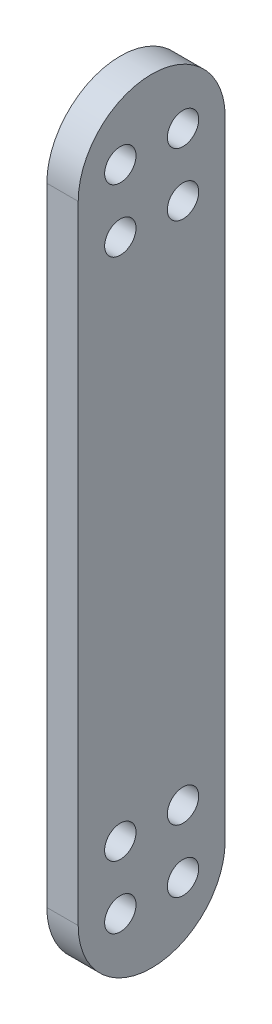
from build123d import *

# Parameters (mm, degrees)
RESSALTO_EXTRUS_O1_DEPTH = 40
ESBO_O2_R                = 5
CORTE_EXTRUS_O1_DEPTH    = 51
ESBO_O3_R                = 2.5
RESSALTO_EXTRUS_O2_DEPTH = 5
ESBO_O4_W                = 80.158201918
ESBO_O4_H                = 76.08775654
CORTE_EXTRUS_O2_DEPTH    = 50


with BuildPart() as part:
    # Esboço1 → Ressalto-extrusão1 (new body)
    with BuildSketch(Plane.XY):
        Polygon((0, 0), (0, 50), (10, 50), (10, 10), (40, 10), (40, 50), (50, 50), (50, 0), align=None)
    extrude(amount=RESSALTO_EXTRUS_O1_DEPTH)

    # Esboço2 → Corte-extrusão1 (cut, through all)
    with BuildSketch(Plane.ZY):
        with Locations((20, 33.697961809)):
            Circle(ESBO_O2_R)
    extrude(amount=-CORTE_EXTRUS_O1_DEPTH, mode=Mode.SUBTRACT)

    # Esboço3 → Ressalto-extrusão2 (add)
    with BuildSketch(Plane.ZY):
        with BuildLine():
            Line((8.284737573, 33.697961809), (8.284737573, 133.697961809))
            ThreePointArc((8.284737573, 133.697961809), (20, 145.413224236), (31.715262427, 133.697961809))
            Line((31.715262427, 133.697961809), (31.715262427, 33.697961809))
            ThreePointArc((31.715262427, 33.697961809), (20, 21.982699383), (8.284737573, 33.697961809))
        make_face()
        with Locations((15, 135.413224236)):
            Circle(ESBO_O3_R, mode=Mode.SUBTRACT)
        with Locations((25, 135.413224236)):
            Circle(ESBO_O3_R, mode=Mode.SUBTRACT)
        with Locations((25, 125.413224236)):
            Circle(ESBO_O3_R, mode=Mode.SUBTRACT)
        with Locations((15, 125.413224236)):
            Circle(ESBO_O3_R, mode=Mode.SUBTRACT)
        with Locations((25, 31.982699383)):
            Circle(ESBO_O3_R, mode=Mode.SUBTRACT)
        with Locations((25, 41.982699383)):
            Circle(ESBO_O3_R, mode=Mode.SUBTRACT)
        with Locations((15, 41.982699383)):
            Circle(ESBO_O3_R, mode=Mode.SUBTRACT)
        with Locations((15, 31.982699383)):
            Circle(ESBO_O3_R, mode=Mode.SUBTRACT)
    extrude(amount=RESSALTO_EXTRUS_O2_DEPTH)

    # Esboço4 → Corte-extrusão2 (cut)
    with BuildSketch(Plane(origin=(50, 0, 0), x_dir=(0, 0, -1), z_dir=(1, 0, 0))):
        with Locations((-9.829245476, 29.588761993)):
            Rectangle(ESBO_O4_W, ESBO_O4_H)
    extrude(amount=-CORTE_EXTRUS_O2_DEPTH, mode=Mode.SUBTRACT)


solid = part.part
